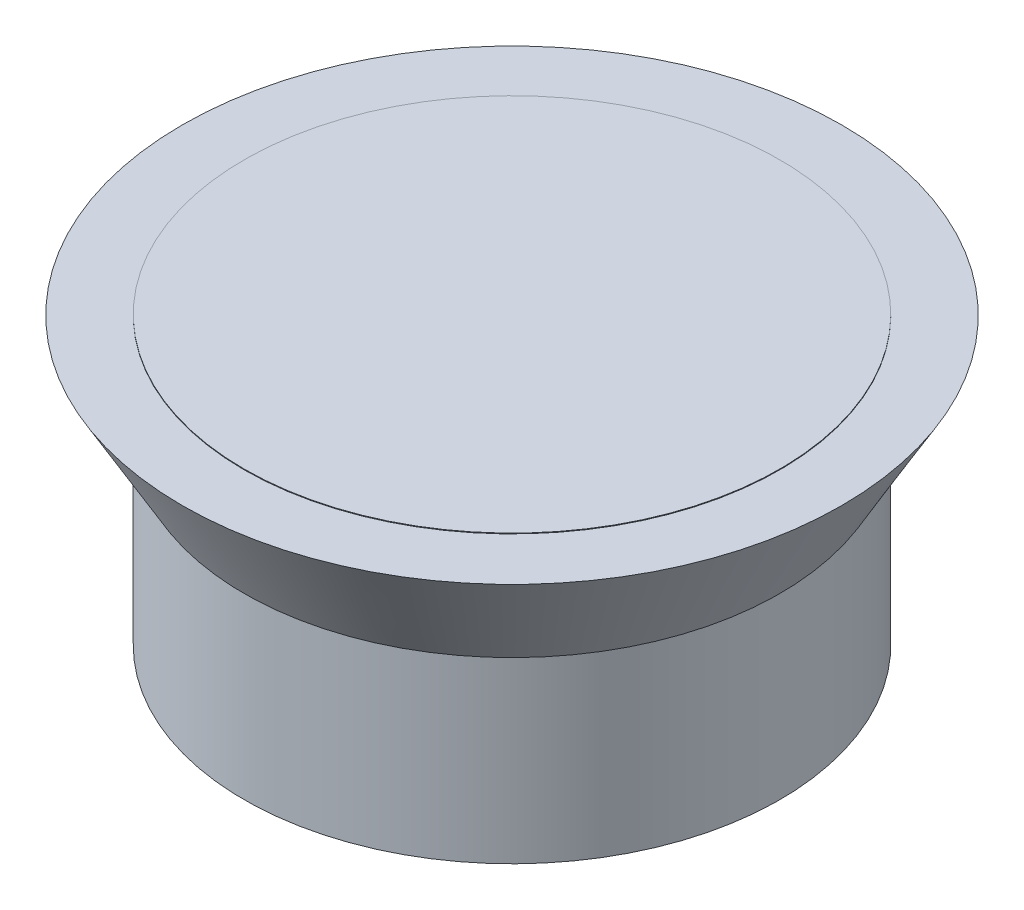
from build123d import *

# Parameters (mm, degrees)
SKETCH2_R           = 9.525
BOSS_EXTRUDE1_DEPTH = 0.0254


with BuildPart() as part:
    # Sketch1 → Revolve1 (revolve)
    with BuildSketch(Plane.XY):
        Polygon((0, 0), (-9.525, 0), (-9.525, 6.35), (-11.724704526, 10.16), (0, 10.16), align=None)
    revolve(axis=Axis((0, 0, 0), (0, 1, 0)))

    # Sketch2 → Boss-Extrude1 (add)
    with BuildSketch(Plane(origin=(0, 10.16, 0), x_dir=(1, 0, 0), z_dir=(0, 1, 0))):
        Circle(SKETCH2_R)
    extrude(amount=BOSS_EXTRUDE1_DEPTH)


solid = part.part
